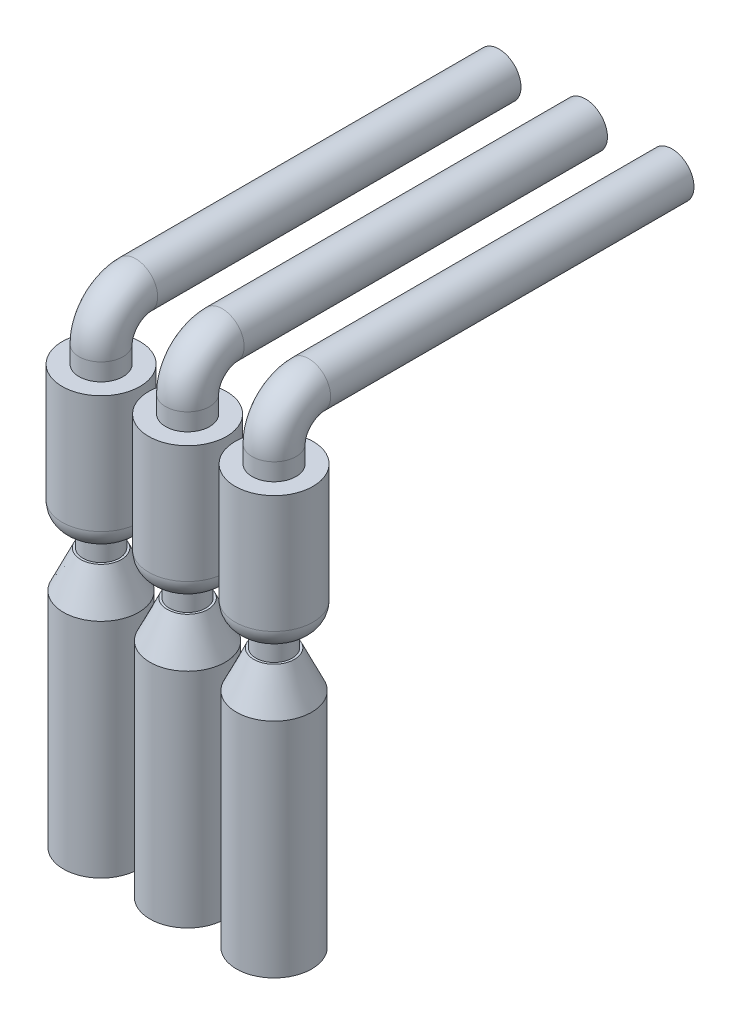
from build123d import *

# Parameters (mm, degrees)
CROQUIS1_R                = 127
SALIENTE_EXTRUIR1_DEPTH   = 2000
SALIENTE_EXTRUIR1_2_DEPTH = 2000
SALIENTE_EXTRUIR1_3_DEPTH = 2000
CROQUIS3_R                = 127
CROQUIS5_R                = 127
CROQUIS6_R                = 127
CROQUIS7_R                = 225
SALIENTE_EXTRUIR2_DEPTH   = 800
REDONDEO1_R               = 120
REDONDEO2_R               = 120
REDONDEO3_R               = 120
CROQUIS8_R                = 105
SALIENTE_EXTRUIR3_DEPTH   = 120
CROQUIS9_R                = 217.5
SALIENTE_EXTRUIR4_DEPTH   = 1500
CHAFL_N1_SIZE             = 100
CHAFL_N1_SIZE2            = 214.450692051
CHAFL_N2_SIZE             = 100
CHAFL_N2_SIZE2            = 214.450692051
CHAFL_N3_SIZE             = 100
CHAFL_N3_SIZE2            = 214.450692051


with BuildPart() as part:
    # Croquis1 → Saliente-Extruir1 (new body)
    with BuildSketch(Plane.XY):
        Circle(CROQUIS1_R)
    extrude(amount=SALIENTE_EXTRUIR1_DEPTH)

    # Barrer1: sweep along a curve in space
    with BuildLine() as barrer1_path:
        Line((0, 0, 2000), (0, 0, 2100))
        ThreePointArc((0, 0, 2100), (0, -58.578643763, 2241.421356237), (0, -200, 2300))
        Line((0, -200, 2300), (0, -300, 2300))
    # Croquis3 → Barrer1 (sweep)
    with BuildSketch(Plane.XY.offset(2000)):
        Circle(CROQUIS3_R)
    sweep(path=barrer1_path.line)



with BuildPart() as body_2:
    # Croquis1 → Saliente-Extruir1 2 (new body)
    with BuildSketch(Plane.XY):
        with Locations((500, 0)):
            Circle(CROQUIS1_R)
    extrude(amount=SALIENTE_EXTRUIR1_2_DEPTH)

    # Barrer2: sweep along a curve in space
    with BuildLine() as barrer2_path:
        Line((500, 0, 2000), (500, 0, 2100))
        ThreePointArc((500, 0, 2100), (500, -58.578643763, 2241.421356237), (500, -200, 2300))
        Line((500, -200, 2300), (500, -300, 2300))
    # Croquis5 → Barrer2 (sweep)
    with BuildSketch(Plane.XY.offset(2000)):
        with Locations((500, 0)):
            Circle(CROQUIS5_R)
    sweep(path=barrer2_path.line)


with BuildPart() as body_3:
    # Croquis1 → Saliente-Extruir1 3 (new body)
    with BuildSketch(Plane.XY):
        with Locations((1000, 0)):
            Circle(CROQUIS1_R)
    extrude(amount=SALIENTE_EXTRUIR1_3_DEPTH)

    # Barrer3: sweep along a curve in space
    with BuildLine() as barrer3_path:
        Line((1000, 0, 2000), (1000, 0, 2100))
        ThreePointArc((1000, 0, 2100), (1000, -58.578643763, 2241.421356237), (1000, -200, 2300))
        Line((1000, -200, 2300), (1000, -300, 2300))
    # Croquis6 → Barrer3 (sweep)
    with BuildSketch(Plane.XY.offset(2000)):
        with Locations((1000, 0)):
            Circle(CROQUIS6_R)
    sweep(path=barrer3_path.line)


with BuildPart() as part_1:
    add(part.part)

    add(body_2.part)  # Saliente-Extruir2 merges body 2

    add(body_3.part)  # Saliente-Extruir2 merges body 3
    # Croquis7 → Saliente-Extruir2 (add)
    with BuildSketch(Plane.XZ.offset(300)):
        with Locations((0, 2300)):
            Circle(CROQUIS7_R)
        with Locations((500, 2300)):
            Circle(CROQUIS7_R)
        with Locations((1000, 2300)):
            Circle(CROQUIS7_R)
    extrude(amount=SALIENTE_EXTRUIR2_DEPTH)

    # Redondeo1
    redondeo1_edges = [part_1.edges().sort_by_distance(p)[0] for p in [
        (775, -1100, 2300),
    ]]
    fillet(redondeo1_edges, radius=REDONDEO1_R)

    # Redondeo2
    redondeo2_edges = [part_1.edges().sort_by_distance(p)[0] for p in [
        (275, -1100, 2300),
    ]]
    fillet(redondeo2_edges, radius=REDONDEO2_R)

    # Redondeo3
    redondeo3_edges = [part_1.edges().sort_by_distance(p)[0] for p in [
        (-225, -1100, 2300),
    ]]
    fillet(redondeo3_edges, radius=REDONDEO3_R)

    # Croquis8 → Saliente-Extruir3 (add)
    with BuildSketch(Plane.XZ.offset(1100)):
        with Locations((1000, 2300)):
            Circle(CROQUIS8_R)
        with Locations((500, 2300)):
            Circle(CROQUIS8_R)
        with Locations((0, 2300)):
            Circle(CROQUIS8_R)
    extrude(amount=SALIENTE_EXTRUIR3_DEPTH)

    # Croquis9 → Saliente-Extruir4 (add)
    with BuildSketch(Plane.XZ.offset(1220)):
        with Locations((1000, 2300)):
            Circle(CROQUIS9_R)
        with Locations((500, 2300)):
            Circle(CROQUIS9_R)
        with Locations((0, 2300)):
            Circle(CROQUIS9_R)
    extrude(amount=SALIENTE_EXTRUIR4_DEPTH)

    # Chaflán1
    chafl_n1_edges = [part_1.edges().sort_by_distance(p)[0] for p in [
        (782.5, -1220, 2300),
    ]]
    chafl_n1_side = [part_1.faces().sort_by_distance(p)[0] for p in [
        (788.651828996, -1220, 2300),
    ]]
    chamfer(chafl_n1_edges, length=CHAFL_N1_SIZE, length2=CHAFL_N1_SIZE2, reference=chafl_n1_side[0])

    # Chaflán2
    chafl_n2_edges = [part_1.edges().sort_by_distance(p)[0] for p in [
        (282.5, -1220, 2300),
    ]]
    chafl_n2_side = [part_1.faces().sort_by_distance(p)[0] for p in [
        (288.651828996, -1220, 2300),
    ]]
    chamfer(chafl_n2_edges, length=CHAFL_N2_SIZE, length2=CHAFL_N2_SIZE2, reference=chafl_n2_side[0])

    # Chaflán3
    chafl_n3_edges = [part_1.edges().sort_by_distance(p)[0] for p in [
        (-217.5, -1220, 2300),
    ]]
    chafl_n3_side = [part_1.faces().sort_by_distance(p)[0] for p in [
        (-211.348171004, -1220, 2300),
    ]]
    chamfer(chafl_n3_edges, length=CHAFL_N3_SIZE, length2=CHAFL_N3_SIZE2, reference=chafl_n3_side[0])


solid = part_1.part
